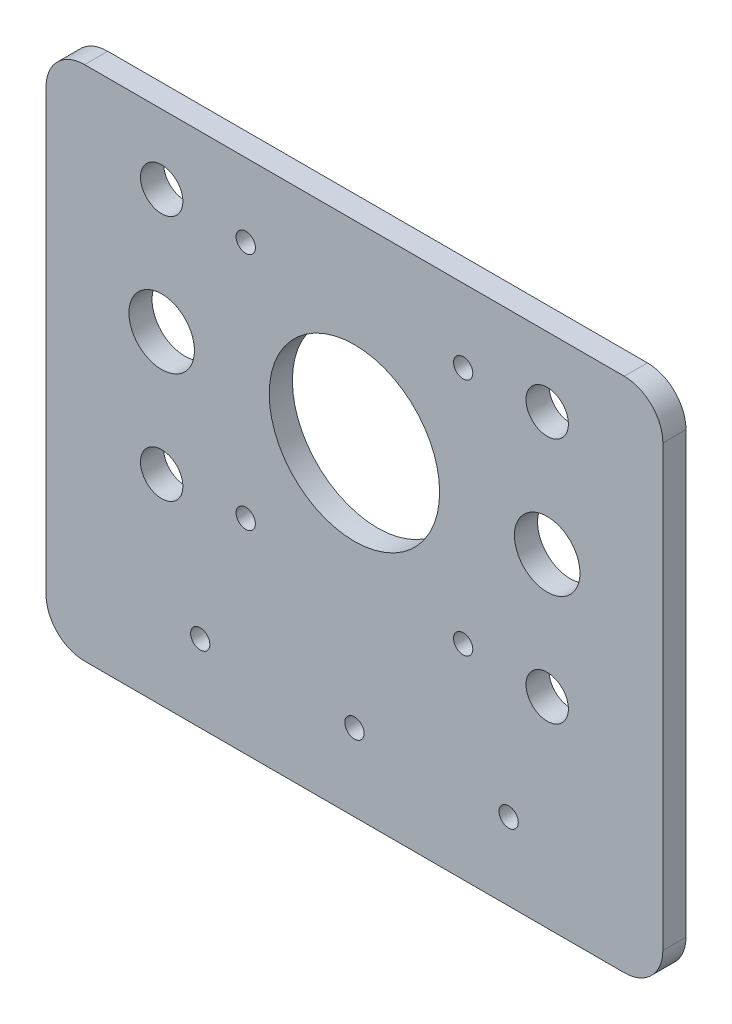
from build123d import *

# Parameters (mm, degrees)
SKETCH_1_R      = 11.05
SKETCH_1_R_2    = 2.75
SKETCH_1_R_3    = 1.25
SKETCH_1_R_4    = 4.25
EXTRUDE_1_DEPTH = 3


with BuildPart() as part:
    # 草图1 → 凸台-拉伸1 (new body)
    with BuildSketch(Plane.XY):
        with BuildLine():
            Line((-40, 20), (-40, -37))
            ThreePointArc((-40, -37), (-38.535533906, -40.535533906), (-35, -42))
            Line((-35, -42), (35, -42))
            ThreePointArc((35, -42), (38.535533906, -40.535533906), (40, -37))
            Line((40, -37), (40, 20))
            ThreePointArc((40, 20), (38.535533906, 23.535533906), (35, 25))
            Line((35, 25), (-35, 25))
            ThreePointArc((-35, 25), (-38.535533906, 23.535533906), (-40, 20))
        make_face()
        Circle(SKETCH_1_R, mode=Mode.SUBTRACT)
        with Locations((-25, 16)):
            Circle(SKETCH_1_R_2, mode=Mode.SUBTRACT)
        with Locations((-25, -16)):
            Circle(SKETCH_1_R_2, mode=Mode.SUBTRACT)
        with Locations((25, -16)):
            Circle(SKETCH_1_R_2, mode=Mode.SUBTRACT)
        with Locations((25, 16)):
            Circle(SKETCH_1_R_2, mode=Mode.SUBTRACT)
        with Locations((0, -32)):
            Circle(SKETCH_1_R_3, mode=Mode.SUBTRACT)
        with Locations((-20, -32)):
            Circle(SKETCH_1_R_3, mode=Mode.SUBTRACT)
        with Locations((20, -32)):
            Circle(SKETCH_1_R_3, mode=Mode.SUBTRACT)
        with Locations((-25, 0)):
            Circle(SKETCH_1_R_4, mode=Mode.SUBTRACT)
        with Locations((25, 0)):
            Circle(SKETCH_1_R_4, mode=Mode.SUBTRACT)
        with Locations((-14.1, 15.5)):
            Circle(SKETCH_1_R_3, mode=Mode.SUBTRACT)
        with Locations((14.1, 15.5)):
            Circle(SKETCH_1_R_3, mode=Mode.SUBTRACT)
        with Locations((14.1, -15.5)):
            Circle(SKETCH_1_R_3, mode=Mode.SUBTRACT)
        with Locations((-14.1, -15.5)):
            Circle(SKETCH_1_R_3, mode=Mode.SUBTRACT)
    extrude(amount=EXTRUDE_1_DEPTH)


solid = part.part
